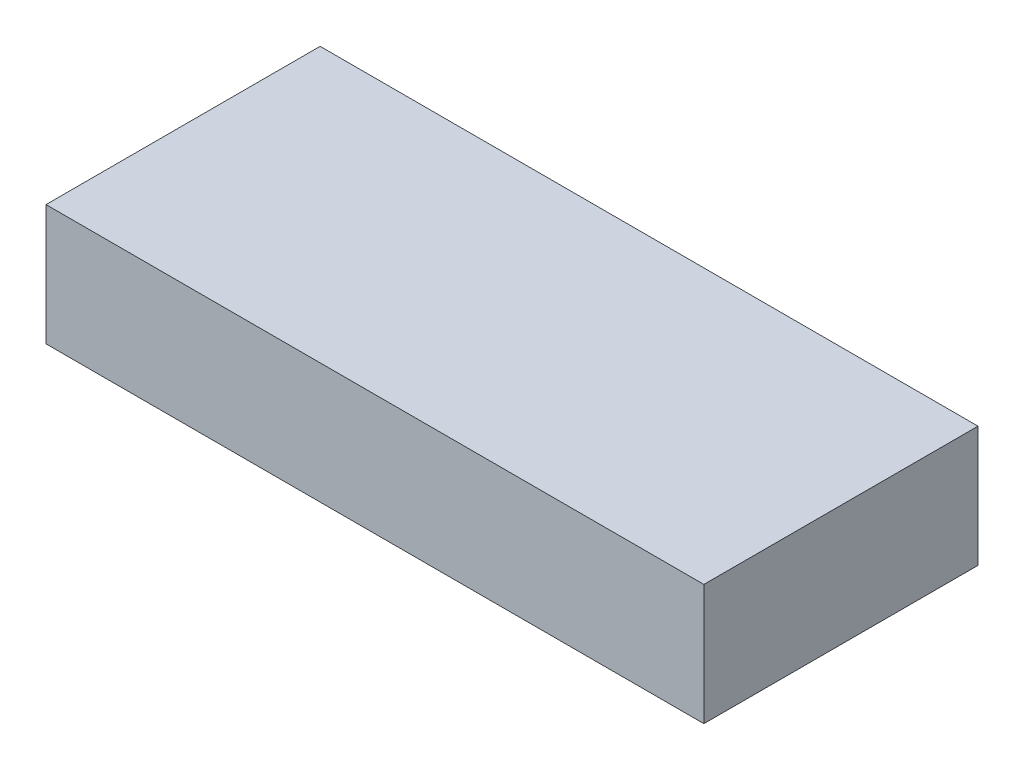
from build123d import *

# Parameters (mm, degrees)
SKETCH1_W           = 60
SKETCH1_H           = 25
BOSS_EXTRUDE1_DEPTH = 11


with BuildPart() as part:
    # Sketch1 → Boss-Extrude1 (new body)
    with BuildSketch(Plane(origin=(0, 0, 0), x_dir=(1, 0, 0), z_dir=(0, 1, 0))):
        with Locations((30, -12.5)):
            Rectangle(SKETCH1_W, SKETCH1_H)
    extrude(amount=BOSS_EXTRUDE1_DEPTH)


solid = part.part
